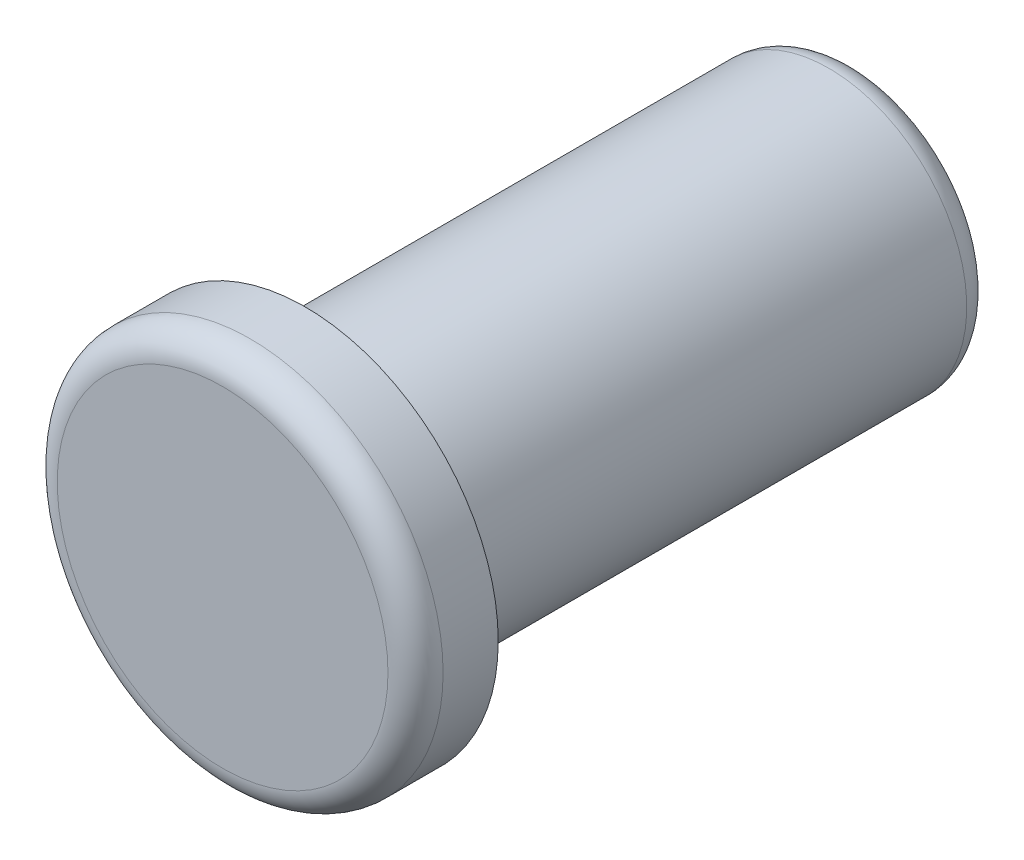
from build123d import *

# Parameters (mm, degrees)
SKICA1_R                = 7
P_IDAT_VYSUNUT_M1_DEPTH = 3
SKICA2_R                = 5
P_IDAT_VYSUNUT_M2_DEPTH = 20
ZAOBLIT1_R              = 1


with BuildPart() as part:
    # Skica1 → Přidat vysunutím1 (new body)
    with BuildSketch(Plane.XY):
        Circle(SKICA1_R)
    extrude(amount=P_IDAT_VYSUNUT_M1_DEPTH)

    # Skica2 → Přidat vysunutím2 (add)
    with BuildSketch(Plane(origin=(0, 0, 0), x_dir=(-1, 0, 0), z_dir=(0, 0, -1))):
        Circle(SKICA2_R)
    extrude(amount=P_IDAT_VYSUNUT_M2_DEPTH)

    # Zaoblit1
    zaoblit1_edges = [part.edges().sort_by_distance(p)[0] for p in [
        (-7, 0, 3),
        (5, 0, -20),
    ]]
    fillet(zaoblit1_edges, radius=ZAOBLIT1_R)


solid = part.part
